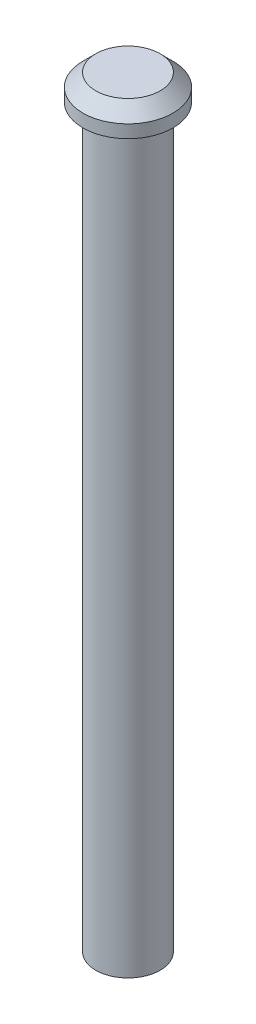
from build123d import *

# Parameters (mm, degrees)
SKETCH1_R           = 2.5
BOSS_EXTRUDE1_DEPTH = 57.2
SKETCH2_R           = 3.5
BOSS_EXTRUDE2_DEPTH = 2
CHAMFER1_SIZE       = 1
SKETCH3_R           = 1.5
CUT_EXTRUDE1_DEPTH  = 5


with BuildPart() as part:
    # Sketch1 → Boss-Extrude1 (new body)
    with BuildSketch(Plane(origin=(0, 0, 0), x_dir=(1, 0, 0), z_dir=(0, 1, 0))):
        Circle(SKETCH1_R)
    extrude(amount=BOSS_EXTRUDE1_DEPTH)

    # Sketch2 → Boss-Extrude2 (add)
    with BuildSketch(Plane(origin=(0, 57.2, 0), x_dir=(1, 0, 0), z_dir=(0, 1, 0))):
        Circle(SKETCH2_R)
    extrude(amount=BOSS_EXTRUDE2_DEPTH)

    # Chamfer1
    chamfer1_edges = [part.edges().sort_by_distance(p)[0] for p in [
        (-3.5, 59.2, 0),
    ]]
    chamfer(chamfer1_edges, length=CHAMFER1_SIZE)

    # Sketch3 → Cut-Extrude1 (cut)
    with BuildSketch(Plane.XZ):
        Circle(SKETCH3_R)
    extrude(amount=-CUT_EXTRUDE1_DEPTH, mode=Mode.SUBTRACT)


solid = part.part
